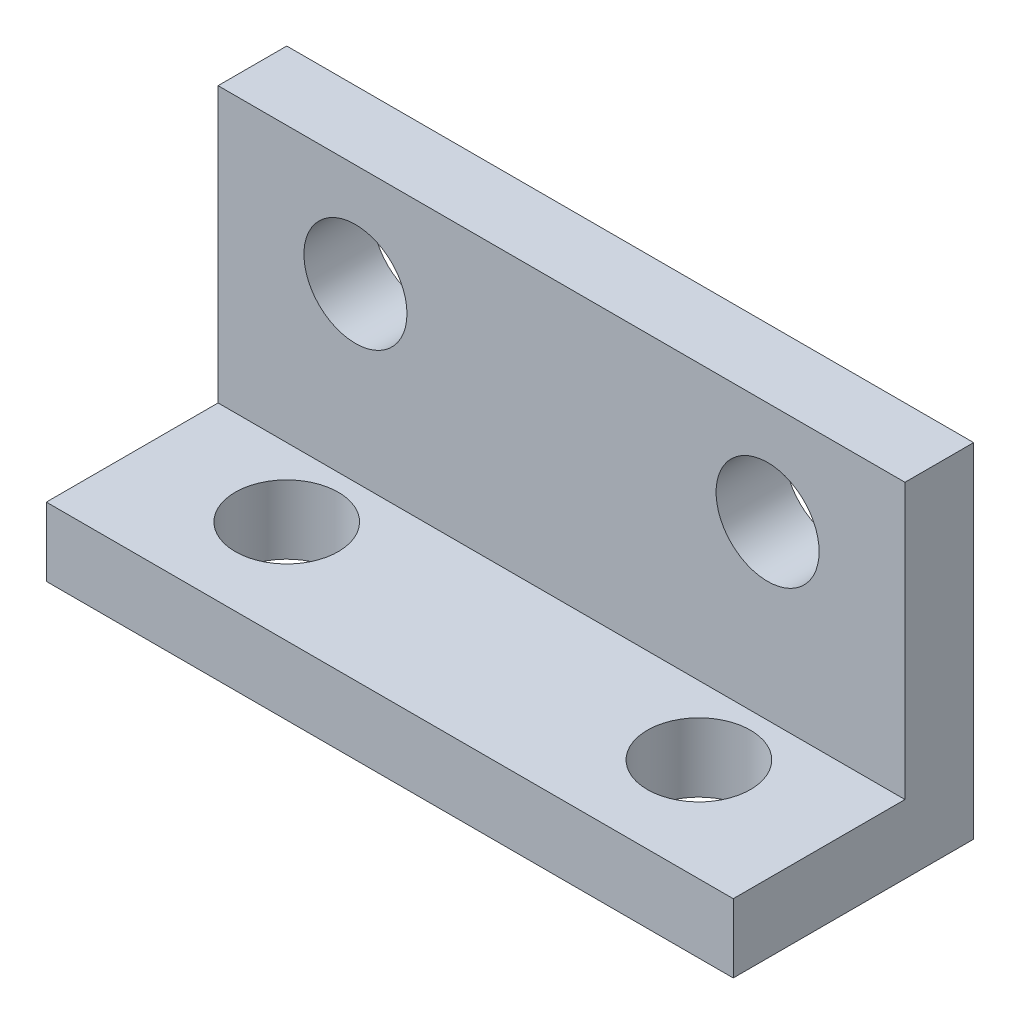
from build123d import *

# Parameters (mm, degrees)
RESSALTO_EXTRUS_O1_DEPTH = 20
ESBO_O2_R                = 1.5
CORTE_EXTRUS_O1_DEPTH    = 3
ESBO_O3_R                = 1.5
CORTE_EXTRUS_O2_DEPTH    = 3


with BuildPart() as part:
    # Esboço1 → Ressalto-extrusão1 (new body)
    with BuildSketch(Plane(origin=(0, 0, 0), x_dir=(0, 0, -1), z_dir=(1, 0, 0))):
        Polygon((0, 0), (0, 10), (-2, 10), (-2, 2), (-7, 2), (-7, 0), align=None)
    extrude(amount=RESSALTO_EXTRUS_O1_DEPTH)

    # Esboço2 → Corte-extrusão1 (cut, through all)
    with BuildSketch(Plane(origin=(0, 2, 0), x_dir=(1, 0, 0), z_dir=(0, 1, 0))):
        with Locations((4, -4)):
            Circle(ESBO_O2_R)
        with Locations((16, -4)):
            Circle(ESBO_O2_R)
    extrude(amount=-CORTE_EXTRUS_O1_DEPTH, mode=Mode.SUBTRACT)

    # Esboço3 → Corte-extrusão2 (cut, through all)
    with BuildSketch(Plane.XY.offset(2)):
        with Locations((4, 7)):
            Circle(ESBO_O3_R)
        with Locations((16, 7)):
            Circle(ESBO_O3_R)
    extrude(amount=-CORTE_EXTRUS_O2_DEPTH, mode=Mode.SUBTRACT)


solid = part.part
